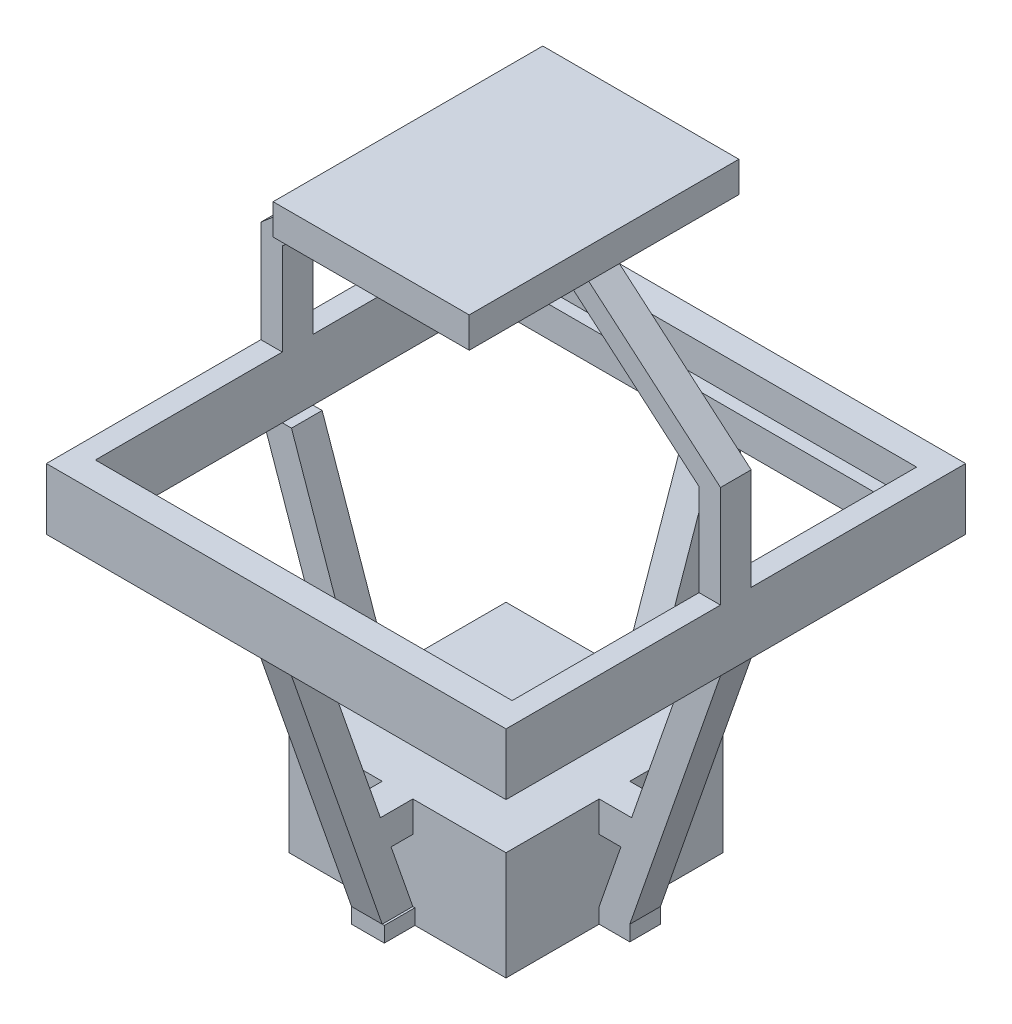
from build123d import *

# Parameters (mm, degrees)
SKETCH2_W                   = 75
SKETCH2_H                   = 75
BOSS_EXTRUDE1_DEPTH         = 5
SKETCH2_2_W                 = 75
SKETCH2_2_H                 = 75
BOSS_EXTRUDE2_DEPTH         = 5
SKETCH4_W                   = 68
SKETCH4_H                   = 66
CUT_EXTRUDE1_DEPTH          = 5
SKETCH5_W                   = 64
SKETCH5_H                   = 62
CUT_EXTRUDE2_DEPTH          = 5
SKETCH14_W                  = 35.4
SKETCH14_H                  = 35.4
BOSS_EXTRUDE9_DEPTH         = 17.7
SKETCH15_W                  = 25.4
SKETCH15_H                  = 25.4
CUT_EXTRUDE3_DEPTH          = 12.7
SKETCH32_R                  = 3
CUT_EXTRUDE6_DEPTH          = 5
SKETCH16_W                  = 32
SKETCH16_H                  = 44
BOSS_EXTRUDE10_DEPTH        = 5
BOSS_EXTRUDE13_DEPTH        = 2.5
BOSS_EXTRUDE14_DEPTH        = 2.5
SKETCH27_W                  = 5
SKETCH27_H                  = 5
SKETCH27_W_2                = 5.344431893
EYEBOLT_BOLT_SUPPORTS_DEPTH = 2.5
BOSS_EXTRUDE15_DEPTH        = 2.5
BOSS_EXTRUDE16_DEPTH        = 2.5
BOSS_EXTRUDE17_DEPTH        = 2.5
BOSS_EXTRUDE18_DEPTH        = 2.5
SKETCH33_W                  = 6.3
SKETCH33_H                  = 5
SKETCH33_W_2                = 5
SKETCH33_H_2                = 6.3
EYEBOLT_MINI_SUPPORTS_DEPTH = 5
SKETCH34_W                  = 2
SKETCH34_H                  = 62
SKETCH34_H_2                = 61.182345807
CUT_EXTRUDE7_DEPTH          = 5


with BuildPart() as part:
    # Sketch2 → Boss-Extrude1 (new body)
    with BuildSketch(Plane(origin=(0, 0, 0), x_dir=(1, 0, 0), z_dir=(0, 1, 0))):
        Rectangle(SKETCH2_W, SKETCH2_H)
    extrude(amount=BOSS_EXTRUDE1_DEPTH)

    # Sketch2_2 → Boss-Extrude2 (add)
    with BuildSketch(Plane(origin=(0, 0, 0), x_dir=(1, 0, 0), z_dir=(0, 1, 0))):
        Rectangle(SKETCH2_2_W, SKETCH2_2_H)
    extrude(amount=-BOSS_EXTRUDE2_DEPTH)

    # Sketch4 → Cut-Extrude1 (cut)
    with BuildSketch(Plane(origin=(0, 5, 0), x_dir=(1, 0, 0), z_dir=(0, 1, 0))):
        Rectangle(SKETCH4_W, SKETCH4_H)
    extrude(amount=-CUT_EXTRUDE1_DEPTH, mode=Mode.SUBTRACT)

    # Sketch5 → Cut-Extrude2 (cut)
    with BuildSketch(Plane(origin=(0, 0, 0), x_dir=(1, 0, 0), z_dir=(0, 1, 0))):
        Rectangle(SKETCH5_W, SKETCH5_H)
    extrude(amount=-CUT_EXTRUDE2_DEPTH, mode=Mode.SUBTRACT)



with BuildPart() as body_2:
    # Sketch14 → Boss-Extrude9 (new body)
    with BuildSketch(Plane(origin=(0, -50, 0), x_dir=(1, 0, 0), z_dir=(0, 1, 0))):
        Rectangle(SKETCH14_W, SKETCH14_H)
    extrude(amount=BOSS_EXTRUDE9_DEPTH)

    # Sketch15 → Cut-Extrude3 (cut)
    with BuildSketch(Plane.XZ.offset(50)):
        Rectangle(SKETCH15_W, SKETCH15_H)
    extrude(amount=-CUT_EXTRUDE3_DEPTH, mode=Mode.SUBTRACT)

    # Sketch32 → Cut-Extrude6 (cut)
    with BuildSketch(Plane(origin=(0, -32.3, 0), x_dir=(1, 0, 0), z_dir=(0, 1, 0))):
        Circle(SKETCH32_R)
    extrude(amount=-CUT_EXTRUDE6_DEPTH, mode=Mode.SUBTRACT)

    # Sketch27 → Eyebolt Bolt Supports (add)
    with BuildSketch(Plane(origin=(0, -50, 0), x_dir=(-1, 0, 0), z_dir=(0, -1, 0))):
        with Locations((-20.2, 0)):
            Rectangle(SKETCH27_W, SKETCH27_H)
        with Locations((20.2, 0)):
            Rectangle(SKETCH27_W, SKETCH27_H)
        with Locations((-0.172215947, -20.2)):
            Rectangle(SKETCH27_W_2, SKETCH27_H)
        with Locations((0, 20.2)):
            Rectangle(SKETCH27_W, SKETCH27_H)
    extrude(amount=-EYEBOLT_BOLT_SUPPORTS_DEPTH)


with BuildPart() as body_3:
    # Sketch16 → Boss-Extrude10 (new body)
    with BuildSketch(Plane(origin=(0, 45, 0), x_dir=(1, 0, 0), z_dir=(0, 1, 0))):
        Rectangle(SKETCH16_W, SKETCH16_H)
    extrude(amount=-BOSS_EXTRUDE10_DEPTH)


with BuildPart() as part_1:
    add(part.part)

    add(body_3.part)  # Boss-Extrude13 merges body 3
    # Sketch21 → Boss-Extrude13 (add)
    with BuildSketch(Plane.XY):
        Polygon((-34, 5), (-37.5, 5), (-37.5, 21.612086276), (-16, 40), (-10.615074094, 40), (-34, 20), align=None)
        Polygon((37.5, 5), (34, 5), (34, 20), (10.615074094, 40), (16, 40), (37.5, 21.612086276), align=None)
    extrude(amount=BOSS_EXTRUDE13_DEPTH)

    # Sketch21_2 → Boss-Extrude14 (add)
    with BuildSketch(Plane.XY):
        Polygon((-34, 20), (-10.615074094, 40), (-16, 40), (-37.5, 21.612086276), (-37.5, 5), (-34, 5), align=None)
        Polygon((34, 5), (37.5, 5), (37.5, 21.612086276), (16, 40), (10.615074094, 40), (34, 20), align=None)
    extrude(amount=-BOSS_EXTRUDE14_DEPTH)


    add(body_2.part)  # Boss-Extrude15 merges body 2
    # Sketch28 → Boss-Extrude15 (add)
    with BuildSketch(Plane.XY):
        Polygon((22.7, -47.5), (37.5, -5), (32.5, -5), (17.7, -47.5), align=None)
        Polygon((-22.7, -47.5), (-37.5, -5), (-32.5, -5), (-17.7, -47.5), align=None)
    extrude(amount=BOSS_EXTRUDE15_DEPTH)

    # Sketch28_2 → Boss-Extrude16 (add)
    with BuildSketch(Plane.XY):
        Polygon((22.7, -47.5), (37.5, -5), (32.5, -5), (17.7, -47.5), align=None)
        Polygon((-22.7, -47.5), (-37.5, -5), (-32.5, -5), (-17.7, -47.5), align=None)
    extrude(amount=-BOSS_EXTRUDE16_DEPTH)

    # Sketch30 → Boss-Extrude17 (add)
    with BuildSketch(Plane(origin=(0, 0, 0), x_dir=(0, 0, -1), z_dir=(1, 0, 0))):
        Polygon((22.7, -47.5), (37.5, -5), (32.5, -5), (17.7, -47.5), align=None)
        Polygon((-37.5, -5), (-22.7, -47.5), (-17.7, -47.5), (-32.5, -5), align=None)
    extrude(amount=BOSS_EXTRUDE17_DEPTH)

    # Sketch30_2 → Boss-Extrude18 (add)
    with BuildSketch(Plane(origin=(0, 0, 0), x_dir=(0, 0, -1), z_dir=(1, 0, 0))):
        Polygon((22.7, -47.5), (37.5, -5), (32.5, -5), (17.7, -47.5), align=None)
        Polygon((-37.5, -5), (-22.7, -47.5), (-17.7, -47.5), (-32.5, -5), align=None)
    extrude(amount=-BOSS_EXTRUDE18_DEPTH)

    # Sketch33 → Eyebolt Mini Supports (add)
    with BuildSketch(Plane(origin=(0, -32.3, 0), x_dir=(1, 0, 0), z_dir=(0, 1, 0))):
        with Locations((20.85, 0)):
            Rectangle(SKETCH33_W, SKETCH33_H)
        with Locations((0, 20.85)):
            Rectangle(SKETCH33_W_2, SKETCH33_H_2)
        with Locations((-20.85, 0)):
            Rectangle(SKETCH33_W, SKETCH33_H)
        with Locations((0, -20.85)):
            Rectangle(SKETCH33_W_2, SKETCH33_H_2)
    extrude(amount=-EYEBOLT_MINI_SUPPORTS_DEPTH)

    # Sketch34 → Cut-Extrude7 (cut)
    with BuildSketch(Plane(origin=(0, 0, 0), x_dir=(1, 0, 0), z_dir=(0, 1, 0))):
        with Locations((-33, 0)):
            Rectangle(SKETCH34_W, SKETCH34_H)
        with Locations((33, 0.408827097)):
            Rectangle(SKETCH34_W, SKETCH34_H_2)
    extrude(amount=-CUT_EXTRUDE7_DEPTH, mode=Mode.SUBTRACT)


solid = part_1.part
